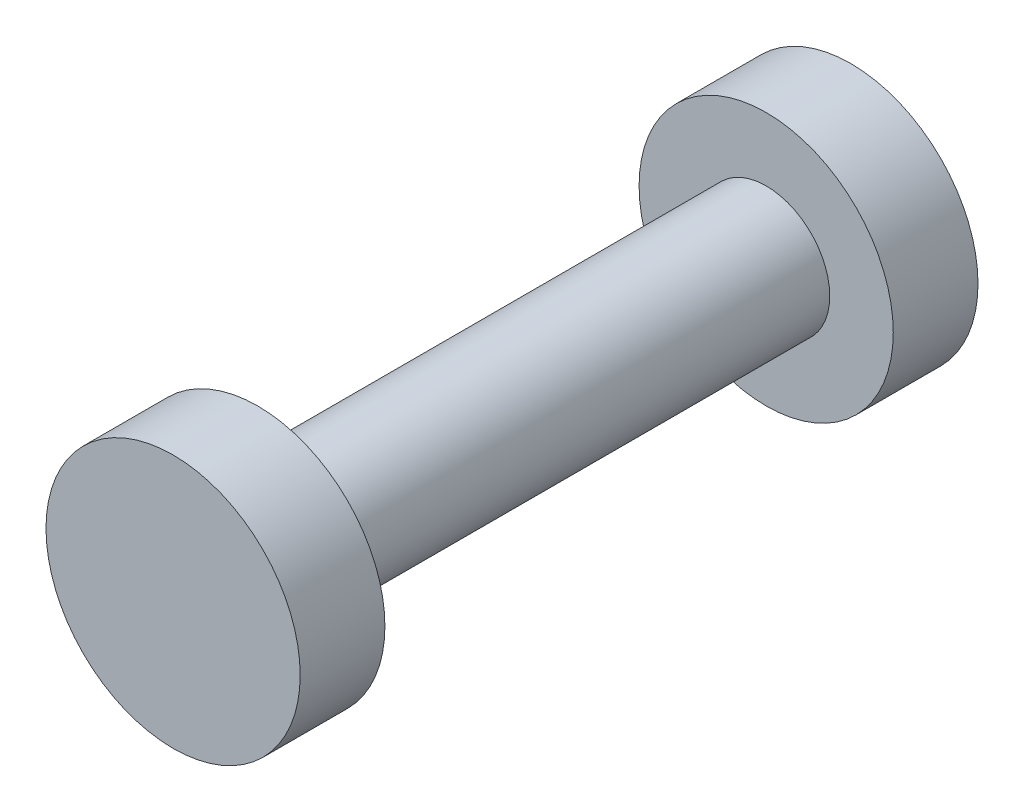
from build123d import *

# Parameters (mm, degrees)
SKETCH1_R           = 1.905
BOSS_EXTRUDE1_DEPTH = 15.24
SKETCH3_R           = 3.81
BOSS_EXTRUDE2_DEPTH = 2.54


with BuildPart() as part:
    # Sketch1 → Boss-Extrude1 (new body)
    with BuildSketch(Plane.XY):
        Circle(SKETCH1_R)
    extrude(amount=BOSS_EXTRUDE1_DEPTH)

    # Sketch3 → Boss-Extrude2 (add)
    with BuildSketch(Plane.XY.offset(15.24)):
        Circle(SKETCH3_R)
    boss_extrude2 = extrude(amount=BOSS_EXTRUDE2_DEPTH)

    # Mirror1: Boss-Extrude2 across plane
    add(boss_extrude2.mirror(Plane.XY.offset(7.62)))


solid = part.part
